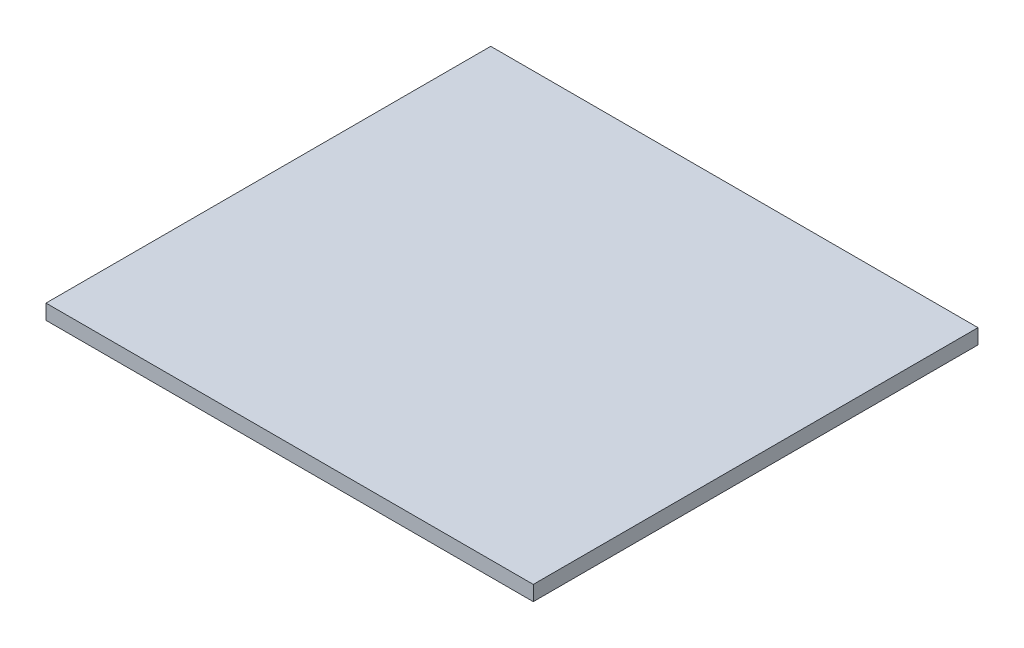
from build123d import *

# Parameters (mm, degrees)
SKETCH1_W           = 206.502
SKETCH1_H           = 188.468
BOSS_EXTRUDE1_DEPTH = 6.35


with BuildPart() as part:
    # Sketch1 → Boss-Extrude1 (new body)
    with BuildSketch(Plane(origin=(0, 0, 0), x_dir=(1, 0, 0), z_dir=(0, 1, 0))):
        with Locations((103.251, 94.234)):
            Rectangle(SKETCH1_W, SKETCH1_H)
    extrude(amount=BOSS_EXTRUDE1_DEPTH)


solid = part.part
